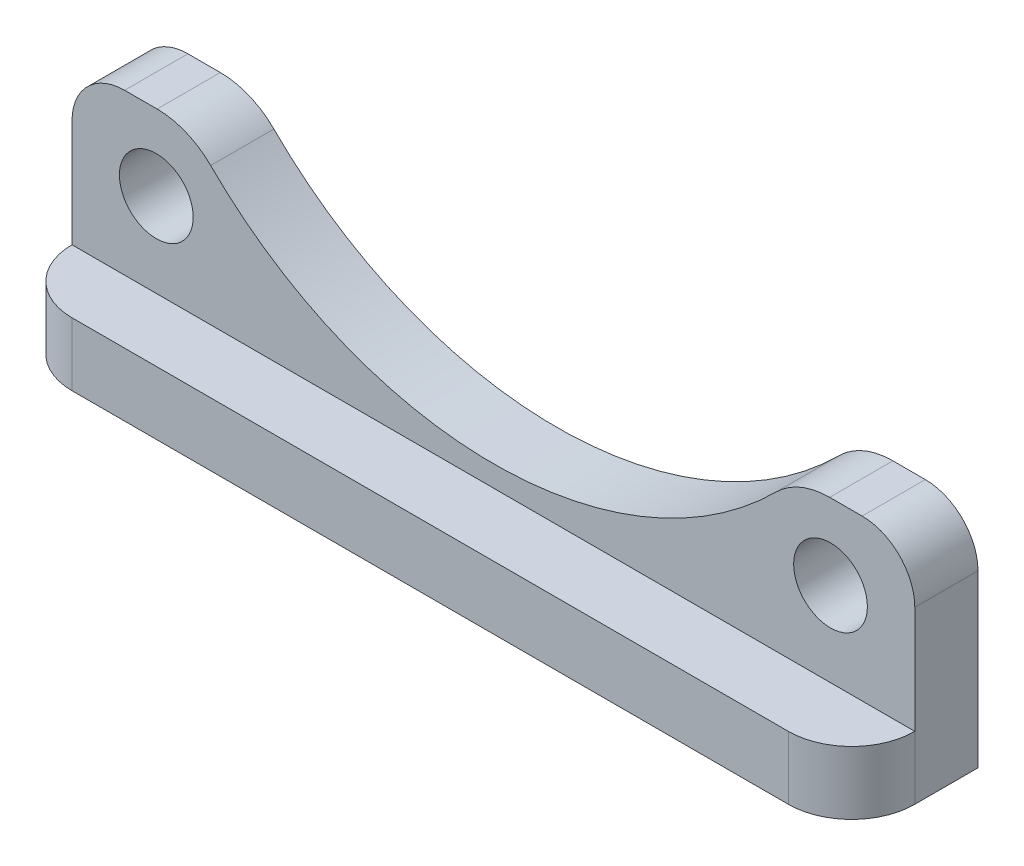
from build123d import *

# Parameters (mm, degrees)
ESBO_O1_W                = 40
ESBO_O1_H                = 10.6
RESSALTO_EXTRUS_O1_DEPTH = 3
ESBO_O2_W                = 40
ESBO_O2_H                = 3
RESSALTO_EXTRUS_O2_DEPTH = 3
FILETE1_R                = 3
ESBO_O3_R                = 1.75
CORTE_EXTRUS_O1_DEPTH    = 3
FILETE2_R                = 2.5
FILETE3_R                = 3.6


with BuildPart() as part:
    # Esboço1 → Ressalto-extrusão1 (new body)
    with BuildSketch(Plane.XY):
        Rectangle(ESBO_O1_W, ESBO_O1_H)
    extrude(amount=RESSALTO_EXTRUS_O1_DEPTH)

    # Esboço2 → Ressalto-extrusão2 (add)
    with BuildSketch(Plane.XY.offset(3)):
        with Locations((0, -3.8)):
            Rectangle(ESBO_O2_W, ESBO_O2_H)
    extrude(amount=RESSALTO_EXTRUS_O2_DEPTH)

    # Filete1
    filete1_edges = [part.edges().sort_by_distance(p)[0] for p in [
        (-20, -3.8, 6),
        (20, -3.8, 6),
    ]]
    fillet(filete1_edges, radius=FILETE1_R)

    # Esboço3 → Corte-extrusão1 (cut)
    with BuildSketch(Plane(origin=(0, 0, 0), x_dir=(-1, 0, 0), z_dir=(0, 0, -1))):
        with BuildLine():
            ThreePointArc((14.39583273, 5.3), (17.811805381, 11.086408762), (19, 17.7))
            ThreePointArc((19, 17.7), (-6.613591238, 35.511805381), (-14.39583273, 5.3))
            Line((-14.39583273, 5.3), (14.39583273, 5.3))
        make_face()
        with BuildLine():
            Line((14.39583273, 5.3), (-14.39583273, 5.3))
            ThreePointArc((-14.39583273, 5.3), (0, -1.3), (14.39583273, 5.3))
        make_face()
        with Locations((16, 1.7)):
            Circle(ESBO_O3_R)
        with Locations((-16, 1.7)):
            Circle(ESBO_O3_R)
    extrude(amount=-CORTE_EXTRUS_O1_DEPTH, mode=Mode.SUBTRACT)

    # Filete2
    filete2_edges = [part.edges().sort_by_distance(p)[0] for p in [
        (-20, 5.3, 1.5),
        (20, 5.3, 1.5),
    ]]
    fillet(filete2_edges, radius=FILETE2_R)

    # Filete3
    filete3_edges = [part.edges().sort_by_distance(p)[0] for p in [
        (-14.39583273, 5.3, 1.5),
        (14.39583273, 5.3, 1.5),
    ]]
    fillet(filete3_edges, radius=FILETE3_R)


solid = part.part
